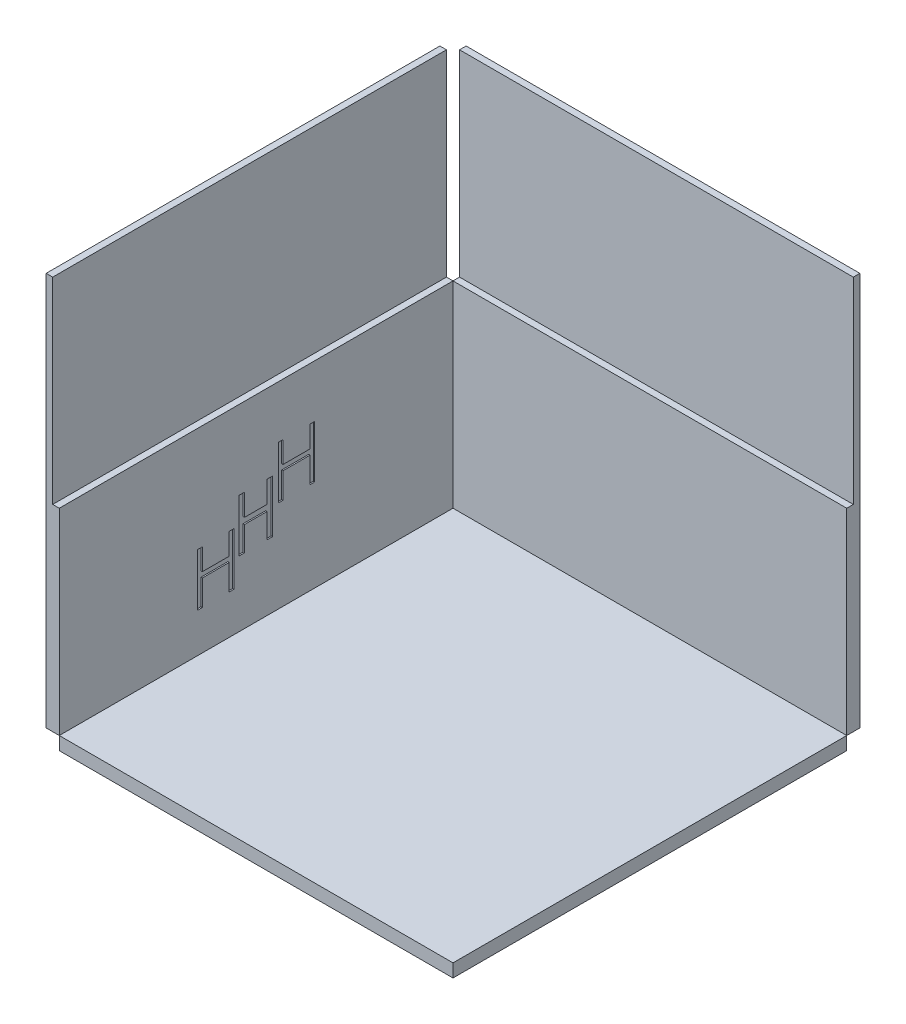
from build123d import *

# Parameters (mm, degrees)
SKETCH1_W           = 300
SKETCH1_H           = 300
BOSS_EXTRUDE1_DEPTH = 10
SKETCH2_W           = 300
SKETCH2_H           = 150
BOSS_EXTRUDE2_DEPTH = 10
BOSS_EXTRUDE3_START = -300
SKETCH3_W           = 300
SKETCH3_H           = 150
BOSS_EXTRUDE3_DEPTH = 10
SKETCH4_W           = 5
SKETCH4_H           = 300
SKETCH4_W_2         = 300
SKETCH4_H_2         = 5
BOSS_EXTRUDE4_DEPTH = 150
CUT_EXTRUDE1_DEPTH  = 1


with BuildPart() as part:
    # Sketch1 → Boss-Extrude1 (new body)
    with BuildSketch(Plane(origin=(0, 0, 0), x_dir=(1, 0, 0), z_dir=(0, 1, 0))):
        with Locations((150, 150)):
            Rectangle(SKETCH1_W, SKETCH1_H)
    extrude(amount=-BOSS_EXTRUDE1_DEPTH)


with BuildPart() as body_2:
    # Sketch2 → Boss-Extrude2 (new body)
    with BuildSketch(Plane(origin=(0, 0, 0), x_dir=(0, 0, -1), z_dir=(1, 0, 0))):
        with Locations((150, 75)):
            Rectangle(SKETCH2_W, SKETCH2_H)
    extrude(amount=-BOSS_EXTRUDE2_DEPTH)



with BuildPart() as body_3:
    # Sketch3 → Boss-Extrude3 (new body)
    with BuildSketch(Plane.XY.offset(BOSS_EXTRUDE3_START)):
        with Locations((150, 75)):
            Rectangle(SKETCH3_W, SKETCH3_H)
    extrude(amount=-BOSS_EXTRUDE3_DEPTH)


with BuildPart() as body_2_1:
    add(body_2.part)

    add(body_3.part)  # Boss-Extrude4 merges body 3
    # Sketch4 → Boss-Extrude4 (add)
    with BuildSketch(Plane(origin=(0, 150, 0), x_dir=(1, 0, 0), z_dir=(0, 1, 0))):
        with Locations((-7.5, 150)):
            Rectangle(SKETCH4_W, SKETCH4_H)
        with Locations((150, 307.5)):
            Rectangle(SKETCH4_W_2, SKETCH4_H_2)
    extrude(amount=BOSS_EXTRUDE4_DEPTH)

    # Sketch5 → Cut-Extrude1 (cut)
    with BuildSketch(Plane(origin=(0, 0, 0), x_dir=(0, 0, -1), z_dir=(1, 0, 0))):
        Polygon((137.012987013, 50), (137.012987013, 90), (141.168831169, 90), (141.168831169, 73.376623377), (158.311688312, 73.376623377), (158.311688312, 90), (162.467532468, 90), (162.467532468, 50), (158.311688312, 50), (158.311688312, 68.701298701), (141.168831169, 68.701298701), (141.168831169, 50), align=None)
        Polygon((105.384615385, 70), (108.974358974, 70), (108.974358974, 53.58974359), (129.487179487, 53.58974359), (129.487179487, 70), (133.076923077, 70), (133.076923077, 30), (129.487179487, 30), (129.487179487, 49.487179487), (108.974358974, 49.487179487), (108.974358974, 30), (105.384615385, 30), align=None)
        Polygon((166.923076923, 110), (170.512820513, 110), (170.512820513, 93.58974359), (191.025641026, 93.58974359), (191.025641026, 110), (194.615384615, 110), (194.615384615, 70), (191.025641026, 70), (191.025641026, 89.487179487), (170.512820513, 89.487179487), (170.512820513, 70), (166.923076923, 70), align=None)
    extrude(amount=-CUT_EXTRUDE1_DEPTH, mode=Mode.SUBTRACT)


solid = Compound([part.part, body_2_1.part])
